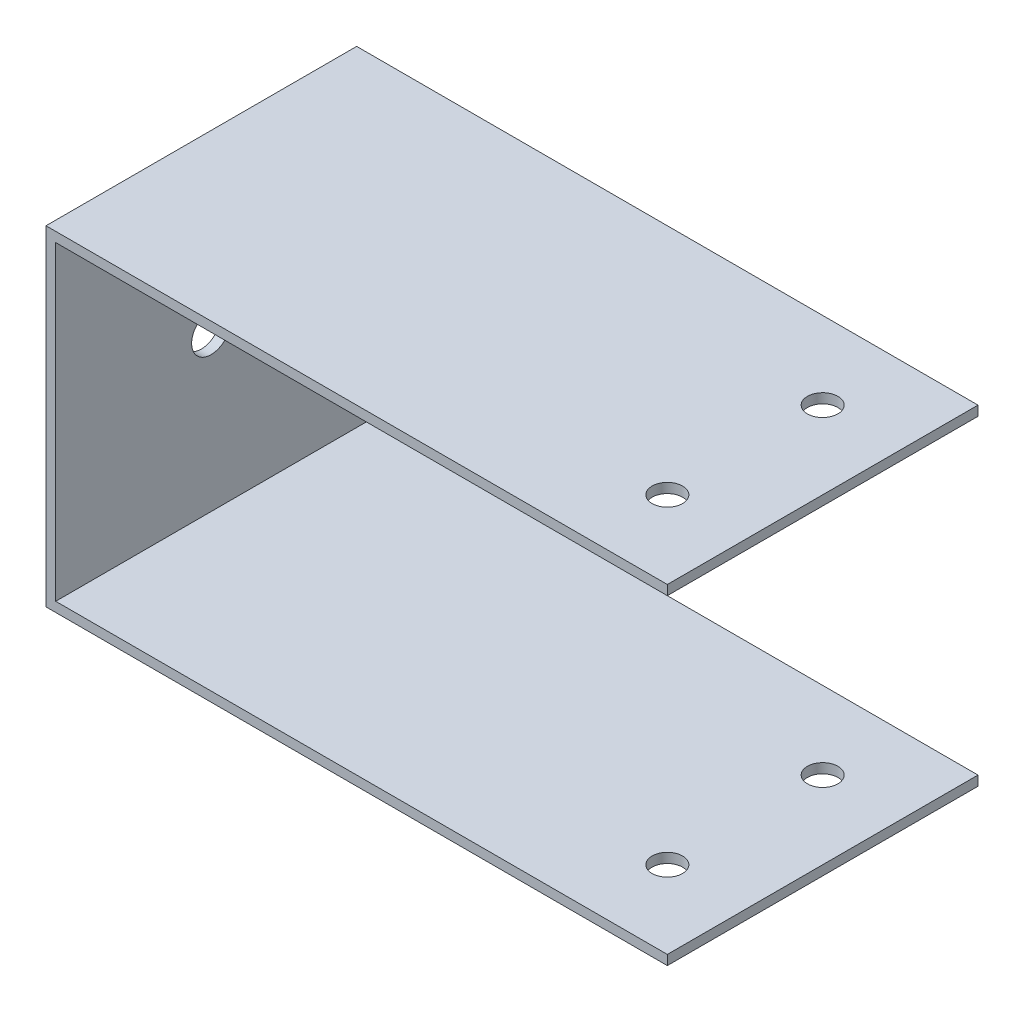
from build123d import *

# Parameters (mm, degrees)
BOSS_EXTRUDE1_DEPTH = 50.8
SKETCH3_R           = 2.4892
CUT_EXTRUDE1_DEPTH  = 54.975
SKETCH4_R           = 3.175
CUT_EXTRUDE2_DEPTH  = 2.5875


with BuildPart() as part:
    # Sketch2 → Boss-Extrude1 (new body)
    with BuildSketch(Plane.XY):
        Polygon((-1.5875, -1.5875), (100.0125, -1.5875), (100.0125, 0), (0, 0), (0, 50.8), (100.0125, 50.8), (100.0125, 52.3875), (-1.5875, 52.3875), align=None)
    extrude(amount=BOSS_EXTRUDE1_DEPTH)

    # Sketch3 → Cut-Extrude1 (cut, through all)
    with BuildSketch(Plane(origin=(0, 52.3875, 0), x_dir=(1, 0, 0), z_dir=(0, 1, 0))):
        with Locations((87.3125, -38.1)):
            Circle(SKETCH3_R)
        with Locations((87.3125, -12.7)):
            Circle(SKETCH3_R)
    extrude(amount=-CUT_EXTRUDE1_DEPTH, mode=Mode.SUBTRACT)

    # Sketch4 → Cut-Extrude2 (cut, through all)
    with BuildSketch(Plane(origin=(0, 0, 0), x_dir=(0, 0, -1), z_dir=(1, 0, 0))):
        with Locations((-25.4, 25.4)):
            Circle(SKETCH4_R)
    extrude(amount=-CUT_EXTRUDE2_DEPTH, mode=Mode.SUBTRACT)


solid = part.part
